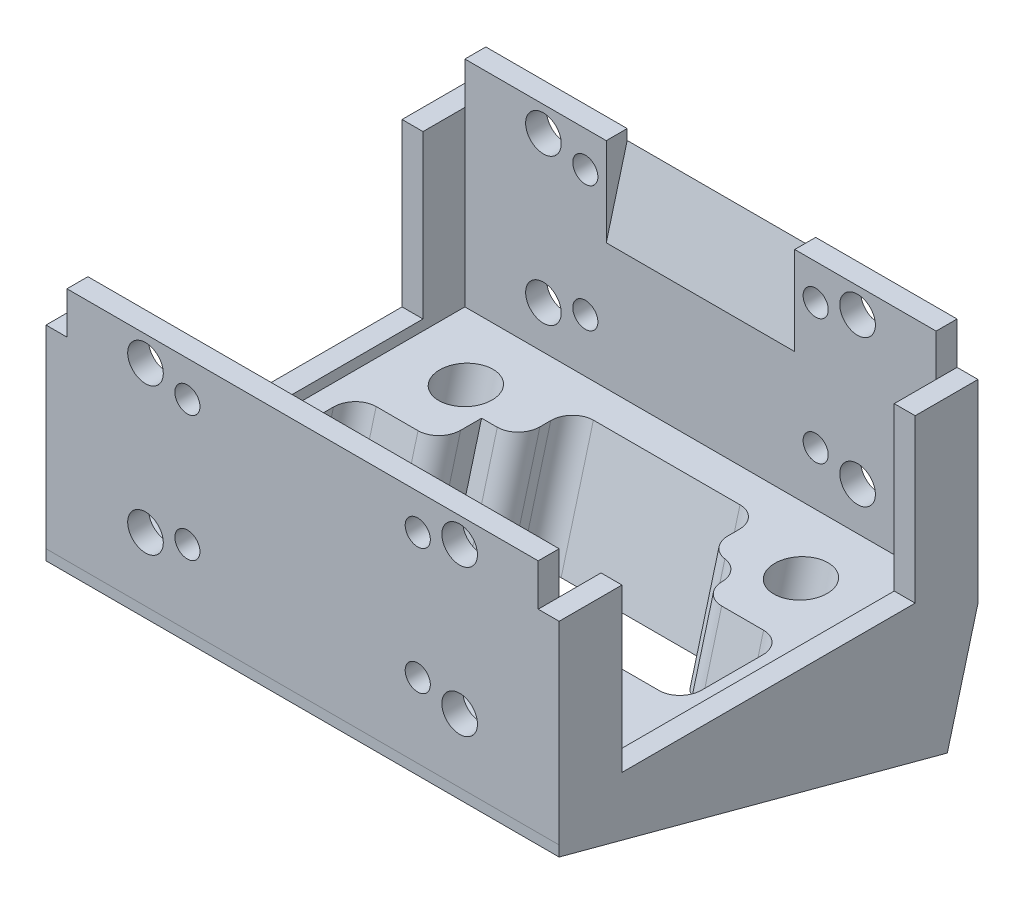
from build123d import *

# Parameters (mm, degrees)
BOSS_EXTRUDE1_DEPTH                              = 49
SKETCH2_W                                        = 45
SKETCH2_H                                        = 2
BOSS_EXTRUDE2_DEPTH                              = 4
SKETCH3_W                                        = 45
SKETCH3_H                                        = 2
BOSS_EXTRUDE3_DEPTH                              = 4
SKETCH4_W                                        = 45
SKETCH4_H                                        = 36
CUT_EXTRUDE1_DEPTH                               = 16.5
CUT_EXTRUDE2_REACH                               = 51
SKETCH5_W                                        = 28
SKETCH5_H                                        = 15.499999955
SKETCH6_W                                        = 28
SKETCH6_H                                        = 15.499999989
CUT_EXTRUDE3_DEPTH                               = 50
CUT_EXTRUDE4_DEPTH                               = 34.052463428
CBORE_FOR_M2_HEX_HEAD_MACHINE_SCREW1_AT_COUNT    = 2
CBORE_FOR_M2_HEX_HEAD_MACHINE_SCREW1_AT_PITCH    = 32
CBORE_FOR_M2_HEX_HEAD_MACHINE_SCREW2_D           = 2.5
CBORE_FOR_M2_HEX_HEAD_MACHINE_SCREW2_DEPTH       = 15.445359267
CBORE_FOR_M2_HEX_HEAD_MACHINE_SCREW2_CBORE_D     = 5
CBORE_FOR_M2_HEX_HEAD_MACHINE_SCREW2_CBORE_DEPTH = 3.850389414
F_3_4_3_4_DIAMETER_HOLE1_D                       = 3.4
F_3_4_3_4_DIAMETER_HOLE1_DEPTH                   = 2
F_2_4_2_4_DIAMETER_HOLE1_D                       = 2.4
F_2_4_2_4_DIAMETER_HOLE1_DEPTH                   = 2
F_3_4_3_4_DIAMETER_HOLE2_D                       = 3.4
F_3_4_3_4_DIAMETER_HOLE2_DEPTH                   = 40
F_2_4_2_4_DIAMETER_HOLE2_D                       = 2.4
F_2_4_2_4_DIAMETER_HOLE2_DEPTH                   = 40
FILLET1_R                                        = 2


with BuildPart() as part:
    # Sketch1 → Boss-Extrude1 (new body)
    with BuildSketch(Plane(origin=(24.5, 0, 0), x_dir=(0, 0, -1), z_dir=(1, 0, 0))):
        Polygon((20, 18.5), (-20, 18.5), (-20, 0), (-20.001723757, -0.999998514), (17.070392977, -10.933442255), (20, 0), align=None)
    extrude(amount=-BOSS_EXTRUDE1_DEPTH)

    # Sketch2 → Boss-Extrude2 (add)
    with BuildSketch(Plane(origin=(0, 18.5, 0), x_dir=(-1, 0, 0), z_dir=(0, 1, 0))):
        with Locations((0, 19)):
            Rectangle(SKETCH2_W, SKETCH2_H)
    extrude(amount=BOSS_EXTRUDE2_DEPTH)

    # Sketch3 → Boss-Extrude3 (add)
    with BuildSketch(Plane(origin=(0, 18.5, 0), x_dir=(-1, 0, 0), z_dir=(0, 1, 0))):
        with Locations((0, -19)):
            Rectangle(SKETCH3_W, SKETCH3_H)
    extrude(amount=BOSS_EXTRUDE3_DEPTH)

    # Sketch4 → Cut-Extrude1 (cut)
    with BuildSketch(Plane(origin=(0, 18.5, 0), x_dir=(-1, 0, 0), z_dir=(0, 1, 0))):
        Rectangle(SKETCH4_W, SKETCH4_H)
    extrude(amount=-CUT_EXTRUDE1_DEPTH, mode=Mode.SUBTRACT)

    # Sketch5 → Cut-Extrude2 (cut, up to next)
    with BuildSketch(Plane(origin=(24.5, 0, 0), x_dir=(0, 0, -1), z_dir=(1, 0, 0)), mode=Mode.PRIVATE) as cut_extrude2_sk1:
        with Locations((0, 10.750000023)):
            Rectangle(SKETCH5_W, SKETCH5_H)
    cut_extrude2_tool1 = extrude(cut_extrude2_sk1.sketch, amount=-CUT_EXTRUDE2_REACH, mode=Mode.PRIVATE) & part.part
    add(cut_extrude2_tool1.solids().sort_by_distance((24.5, 10.75, 0))[0], mode=Mode.SUBTRACT)

    # Sketch6 → Cut-Extrude3 (cut, through all)
    with BuildSketch(Plane.ZY.offset(24.5)):
        with Locations((0, 10.750000006)):
            Rectangle(SKETCH6_W, SKETCH6_H)
    extrude(amount=-CUT_EXTRUDE3_DEPTH, mode=Mode.SUBTRACT)

    # Sketch7 → Cut-Extrude4 (cut, through all)
    with BuildSketch(Plane(origin=(0, -5.933442255, 1.589861061), x_dir=(1, 0, 0), z_dir=(0, -0.965925826, 0.258819045))):
        with BuildLine():
            Line((-9, -8.75), (-9, -13.75))
            Line((-9, -13.75), (9, -13.75))
            Line((9, -13.75), (9, -10.71870086))
            ThreePointArc((9, -10.71870086), (9.500097813, -9.395714303), (10.750293429, -8.73435043))
            ThreePointArc((10.750293429, -8.73435043), (11.989102808, -8.085784512), (12.500293429, -6.784258263))
            ThreePointArc((12.500293429, -6.784258263), (13.097950879, -5.392242266), (14.5, -4.818516526))
            Line((14.5, -4.818516526), (20.5, -4.818516526))
            Line((20.5, -4.818516526), (20.5, 4.818516526))
            Line((20.5, 4.818516526), (14.499827541, 4.818516526))
            ThreePointArc((14.499827541, 4.818516526), (13.092195397, 5.397752032), (12.499913771, 6.79994478))
            ThreePointArc((12.499913771, 6.79994478), (11.993841738, 8.11119891), (10.75, 8.765686517))
            ThreePointArc((10.75, 8.765686517), (9.5, 9.427124344), (9, 10.75))
            Line((9, 10.75), (9, 13.75))
            Line((9, 13.75), (-9, 13.75))
            Line((-9, 13.75), (-9, 10.71870086))
            ThreePointArc((-9, 10.71870086), (-9.500097813, 9.395714303), (-10.750293429, 8.73435043))
            ThreePointArc((-10.750293429, 8.73435043), (-11.989102808, 8.085784512), (-12.500293429, 6.784258263))
            ThreePointArc((-12.500293429, 6.784258263), (-13.097950879, 5.392242266), (-14.5, 4.818516526))
            Line((-14.5, 4.818516526), (-20.5, 4.818516526))
            Line((-20.5, 4.818516526), (-20.5, -4.818516526))
            Line((-20.5, -4.818516526), (-12.5, -4.818516526))
            Line((-12.5, -4.818516526), (-12.5, -8.75))
            Line((-12.5, -8.75), (-9, -8.75))
        make_face()
    extrude(amount=-CUT_EXTRUDE4_DEPTH, mode=Mode.SUBTRACT)

    # Sketch8 → CBORE for M2 Hex Head Machine Screw1 (revolve, cut)
    with BuildSketch(Plane(origin=(-16, 2.647047613, -11.767559682), x_dir=(0, 0.258819045, 0.965925826), z_dir=(1, 0, 0))):
        Polygon((0, 0), (0, 21.3402415), (1.25, 21.3402415), (1.25, 9.745271647), (2.5, 9.745271647), (2.5, 0), align=None)
    cbore_for_m2_hex_head_machine_screw1 = revolve(axis=Axis((-16, 8.78067661, -13.411060619), (0, -0.965925826, 0.258819045)), mode=Mode.SUBTRACT)

    # CBORE for M2 Hex Head Machine Screw1 at: CBORE for M2 Hex Head Machine Screw1 ×2
    with Locations(*[(i * CBORE_FOR_M2_HEX_HEAD_MACHINE_SCREW1_AT_PITCH, 0, 0) for i in range(1, CBORE_FOR_M2_HEX_HEAD_MACHINE_SCREW1_AT_COUNT)]):
        add(cbore_for_m2_hex_head_machine_screw1, mode=Mode.SUBTRACT)

    # CBORE for M2 Hex Head Machine Screw2
    with Locations(Plane(origin=(0, -0.282400026, 0.075668859), x_dir=(1, 0, 0), z_dir=(0, 0.965925826, -0.258819045))):
        with Locations((-16, -11.318516526), (16, -11.318516526)):
            CounterBoreHole(CBORE_FOR_M2_HEX_HEAD_MACHINE_SCREW2_D / 2, CBORE_FOR_M2_HEX_HEAD_MACHINE_SCREW2_CBORE_D / 2, CBORE_FOR_M2_HEX_HEAD_MACHINE_SCREW2_CBORE_DEPTH, depth=CBORE_FOR_M2_HEX_HEAD_MACHINE_SCREW2_DEPTH)

    # Ø3.4 (3.4) Diameter Hole1
    with Locations(Plane.XY.offset(-18)):
        with Locations((15, 6.1), (-15, 6.1), (15, 20.1), (-15, 20.1)):
            Hole(F_3_4_3_4_DIAMETER_HOLE1_D / 2, depth=F_3_4_3_4_DIAMETER_HOLE1_DEPTH)

    # Ø2.4 (2.4) Diameter Hole1
    with Locations(Plane.XY.offset(-18)):
        with Locations((-11, 19.1), (-11, 7.1), (11, 19.1), (11, 7.1)):
            Hole(F_2_4_2_4_DIAMETER_HOLE1_D / 2, depth=F_2_4_2_4_DIAMETER_HOLE1_DEPTH)

    # Ø3.4 (3.4) Diameter Hole2
    with Locations(Plane.XY.offset(20)):
        with Locations((15, 6.1), (-15, 6.1), (15, 20.1), (-15, 20.1)):
            Hole(F_3_4_3_4_DIAMETER_HOLE2_D / 2, depth=F_3_4_3_4_DIAMETER_HOLE2_DEPTH)

    # Ø2.4 (2.4) Diameter Hole2
    with Locations(Plane.XY.offset(20)):
        with Locations((-11, 19.1), (-11, 7.1), (11, 19.1), (11, 7.1)):
            Hole(F_2_4_2_4_DIAMETER_HOLE2_D / 2, depth=F_2_4_2_4_DIAMETER_HOLE2_DEPTH)

    # Fillet1
    fillet1_edges = [part.edges().sort_by_distance(p)[0] for p in [
        (-9, -3.09905445, -8.228277441),
        (-12.5, -2.590283051, -4.294431133),
        (-20.5, -2.590283051, -4.294431133),
        (-20.5, -1.343159204, 5.348393808),
        (-9, -0.187340192, 14.285245134),
        (9, -0.187340192, 14.285245134),
        (20.5, -1.343159204, 5.348393808),
        (20.5, -2.590283051, -4.294431133),
        (9, -3.746102063, -13.231282458),
        (-9, -3.746102063, -13.231282458),
    ]]
    fillet(fillet1_edges, radius=FILLET1_R)


solid = part.part
